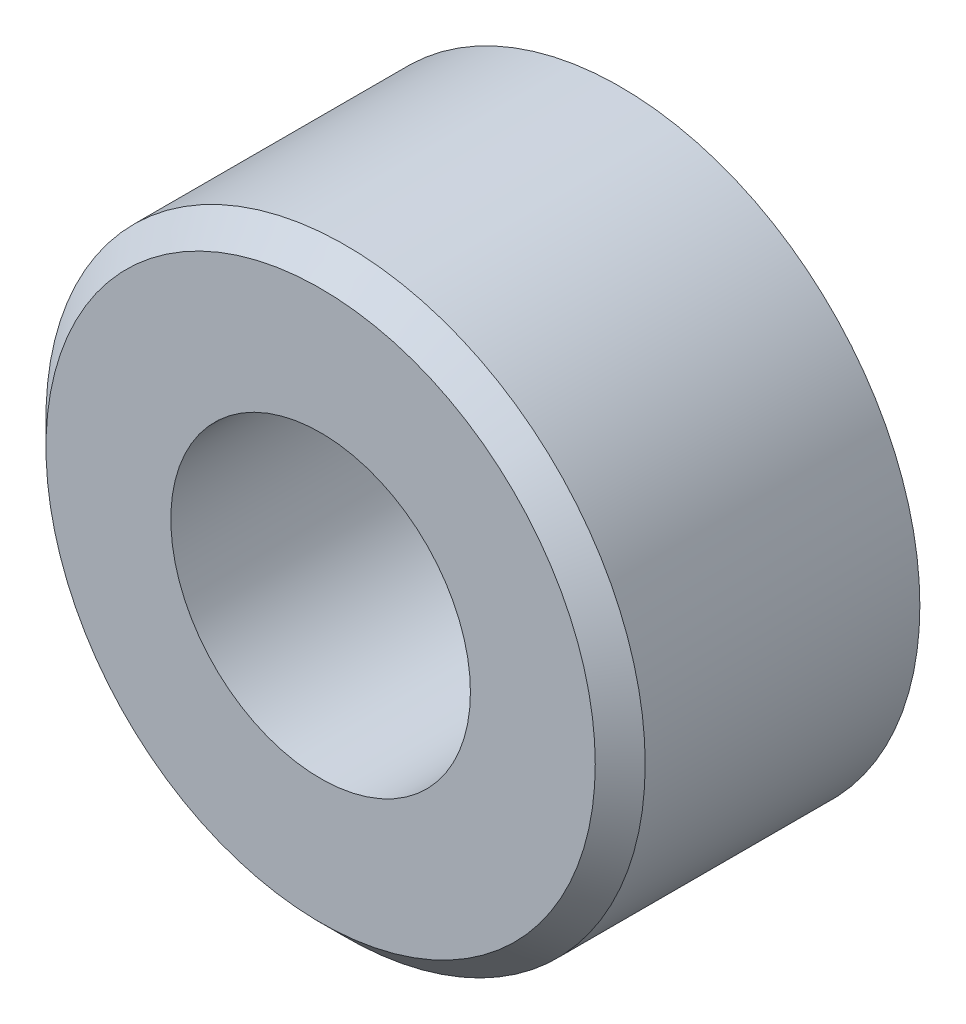
from build123d import *

# Parameters (mm, degrees)
SKETCH1_R           = 6
SKETCH1_R_2         = 3
BOSS_EXTRUDE1_DEPTH = 6
CHAMFER1_SIZE       = 0.5


with BuildPart() as part:
    # Sketch1 → Boss-Extrude1 (new body)
    with BuildSketch(Plane.XY):
        Circle(SKETCH1_R)
        Circle(SKETCH1_R_2, mode=Mode.SUBTRACT)
    extrude(amount=BOSS_EXTRUDE1_DEPTH)

    # Chamfer1
    chamfer1_edges = [part.edges().sort_by_distance(p)[0] for p in [
        (-6, 0, 6),
    ]]
    chamfer(chamfer1_edges, length=CHAMFER1_SIZE)


solid = part.part
